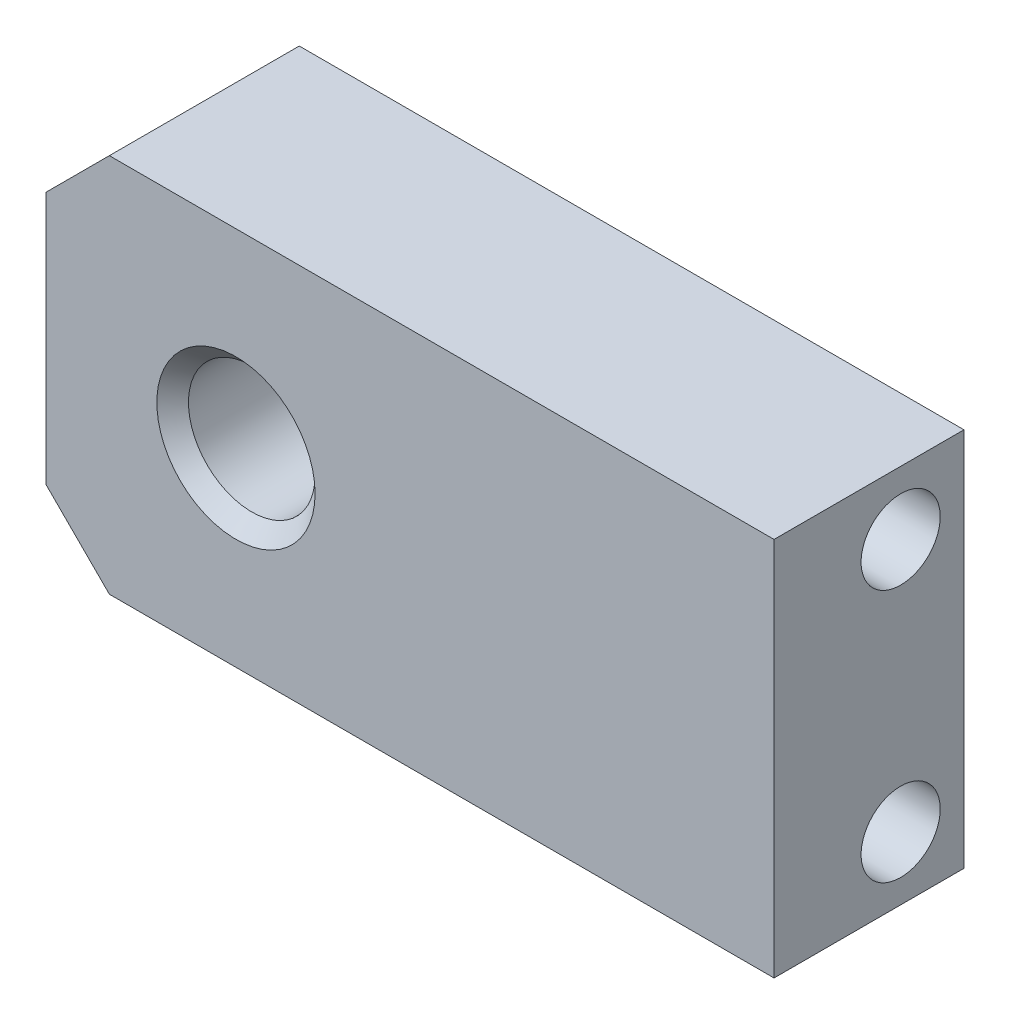
from build123d import *

# Parameters (mm, degrees)
SKETCH5_R                 = 2
BOSS_EXTRUDE3_DEPTH       = 6
CHAMFER1_SIZE             = 0.5
M3X0_5_TAPPED_HOLE2_D     = 2.5
M3X0_5_TAPPED_HOLE2_DEPTH = 10
M3X0_5_TAPPED_HOLE2_TIP   = 0.751075774


with BuildPart() as part:
    # Sketch5 → Boss-Extrude3 (new body)
    with BuildSketch(Plane.XY):
        Polygon((-9.5, -6), (-11.5, -4), (-11.5, 4), (-9.5, 6), (11.5, 6), (11.5, -6), align=None)
        with Locations((-5.5, 0)):
            Circle(SKETCH5_R, mode=Mode.SUBTRACT)
    extrude(amount=BOSS_EXTRUDE3_DEPTH)

    # Chamfer1
    chamfer1_edges = [part.edges().sort_by_distance(p)[0] for p in [
        (-7.5, 0, 0),
        (-7.5, 0, 6),
    ]]
    chamfer(chamfer1_edges, length=CHAMFER1_SIZE)

    # M3x0.5 Tapped Hole2
    with Locations(Plane(origin=(11.5, 4, 2), x_dir=(0, 0, 1), z_dir=(1, 0, 0))):
        with Locations((0, 0), (0, 8)):
            Hole(M3X0_5_TAPPED_HOLE2_D / 2, depth=M3X0_5_TAPPED_HOLE2_DEPTH)
            with Locations((0, 0, -(M3X0_5_TAPPED_HOLE2_DEPTH + M3X0_5_TAPPED_HOLE2_TIP / 2))):  # 118° drill point
                Cone(0, M3X0_5_TAPPED_HOLE2_D / 2, M3X0_5_TAPPED_HOLE2_TIP, mode=Mode.SUBTRACT)


solid = part.part
